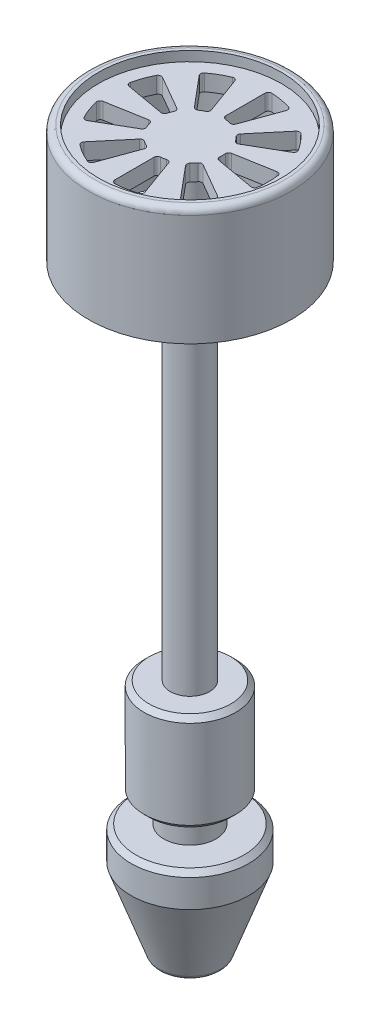
from build123d import *

# Parameters (mm, degrees)
REDONDEO1_R                       = 2
CHAFL_N1_SIZE                     = 1.5
REDONDEO2_R                       = 2
CORTAR_EXTRUIR1_REACH             = 218.983
CORTAR_EXTRUIR1_DIRECTION_2_DEPTH = 4


with BuildPart() as part:
    # Croquis1 → Revolución1 (revolve)
    with BuildSketch(Plane.XY):
        Polygon((97.681062899, 120), (97.681062899, 0), (97.681062899, -3.982649478), (89.681062899, -3.982649478), (89.681062899, -33.982649478), (95.681062899, -33.982649478), (95.681062899, -41.982649478), (85.681062899, -41.982649478), (85.681062899, -51.982649478), (94.681062899, -76.982649478), (97.681062899, -76.982649478), (97.681062899, -60.982649478), (103.681062899, -60.982649478), (103.681062899, 140), (75.681062899, 140), (75.681062899, 143), (72.681062899, 143), (72.681062899, 107), (75.681062899, 107), (75.681062899, 135), (97.681062899, 135), align=None)
    revolve(axis=Axis((103.681062899, -60.982649478, 0), (0, 1, 0)))

    # Redondeo1
    redondeo1_edges = [part.edges().sort_by_distance(p)[0] for p in [
        (134.681062899, 143, 0),
    ]]
    fillet(redondeo1_edges, radius=REDONDEO1_R)

    # Chaflán1
    chafl_n1_edges = [part.edges().sort_by_distance(p)[0] for p in [
        (121.681062899, -41.982649478, 0),
        (117.681062899, -33.982649478, 0),
        (117.681062899, -3.982649478, 0),
    ]]
    chamfer(chafl_n1_edges, length=CHAFL_N1_SIZE)

    # Redondeo2
    redondeo2_edges = [part.edges().sort_by_distance(p)[0] for p in [
        (112.681062899, -76.982649478, 0),
    ]]
    fillet(redondeo2_edges, radius=REDONDEO2_R)

    # Croquis2 → Cortar-Extruir1 (cut, up to next)
    with BuildSketch(Plane(origin=(0, 140, 0), x_dir=(1, 0, 0), z_dir=(0, 1, 0)), mode=Mode.PRIVATE) as cortar_extruir1_sk1:
        with BuildLine():
            Line((103.681062899, 10.95445115), (103.681062899, 22.978250586))
            ThreePointArc((103.681062899, 22.978250586), (103.989498824, 23.700565705), (104.72454116, 23.977304959))
            ThreePointArc((104.72454116, 23.977304959), (107.848619163, 23.635386072), (110.901235356, 22.888187121))
            ThreePointArc((110.901235356, 22.888187121), (111.497298816, 22.376738), (111.540087458, 21.592492514))
            Line((111.540087458, 21.592492514), (107.427705852, 10.293816911))
            ThreePointArc((107.427705852, 10.293816911), (106.951432292, 9.749697802), (106.232835928, 9.668942776))
            ThreePointArc((106.232835928, 9.668942776), (105.417544676, 9.84807753), (104.590153808, 9.958591955))
            ThreePointArc((104.590153808, 9.958591955), (103.942513953, 10.280251288), (103.681062899, 10.95445115))
        make_face()
    cortar_extruir1_tool1 = extrude(cortar_extruir1_sk1.sketch, amount=-CORTAR_EXTRUIR1_REACH, mode=Mode.PRIVATE) & part.part
    add(cortar_extruir1_tool1.solids().sort_by_distance((106.784802, 140, -17.602181))[0], mode=Mode.SUBTRACT)
    # Croquis2 → Cortar-Extruir1 (cut, up to next)
    with BuildSketch(Plane(origin=(0, 140, 0), x_dir=(1, 0, 0), z_dir=(0, 1, 0)), mode=Mode.PRIVATE) as cortar_extruir1_sk2:
        with BuildLine():
            Line((110.722448369, 8.391596431), (118.451197668, 17.602361174))
            ThreePointArc((118.451197668, 17.602361174), (119.151768503, 17.957427866), (119.892728164, 17.696946328))
            ThreePointArc((119.892728164, 17.696946328), (122.066129534, 15.426902632), (123.924278978, 12.892331162))
            ThreePointArc((123.924278978, 12.892331162), (124.052136921, 12.117396199), (123.580811641, 11.489125293))
            Line((123.580811641, 11.489125293), (113.16789588, 5.477225575))
            ThreePointArc((113.16789588, 5.477225575), (112.453296145, 5.366548899), (111.850911063, 5.766591799))
            ThreePointArc((111.850911063, 5.766591799), (111.34150733, 6.427876097), (110.778726457, 7.044371656))
            ThreePointArc((110.778726457, 7.044371656), (110.489364179, 7.707071875), (110.722448369, 8.391596431))
        make_face()
    cortar_extruir1_tool2 = extrude(cortar_extruir1_sk2.sketch, amount=-CORTAR_EXTRUIR1_REACH, mode=Mode.PRIVATE) & part.part
    add(cortar_extruir1_tool2.solids().sort_by_distance((117.373129, 140, -11.489008))[0], mode=Mode.SUBTRACT)
    # Croquis2 → Cortar-Extruir1 (cut, up to next)
    with BuildSketch(Plane(origin=(0, 140, 0), x_dir=(1, 0, 0), z_dir=(0, 1, 0)), mode=Mode.PRIVATE) as cortar_extruir1_sk3:
        with BuildLine():
            Line((114.469091322, 1.90222048), (126.310222227, 3.99013134))
            ThreePointArc((126.310222227, 3.99013134), (127.075123092, 3.811809954), (127.475296818, 3.13598983))
            ThreePointArc((127.475296818, 3.13598983), (127.681062899, 0), (127.475296818, -3.13598983))
            ThreePointArc((127.475296818, -3.13598983), (127.075123092, -3.811809954), (126.310222227, -3.99013134))
            Line((126.310222227, -3.99013134), (114.469091322, -1.90222048))
            ThreePointArc((114.469091322, -1.90222048), (113.850534569, -1.527667877), (113.646223445, -0.83401157))
            ThreePointArc((113.646223445, -0.83401157), (113.681062899, 0), (113.646223445, 0.83401157))
            ThreePointArc((113.646223445, 0.83401157), (113.850534569, 1.527667877), (114.469091322, 1.90222048))
        make_face()
    cortar_extruir1_tool3 = extrude(cortar_extruir1_sk3.sketch, amount=-CORTAR_EXTRUIR1_REACH, mode=Mode.PRIVATE) & part.part
    add(cortar_extruir1_tool3.solids().sort_by_distance((121.554786, 140, 0))[0], mode=Mode.SUBTRACT)
    # Croquis2 → Cortar-Extruir1 (cut, up to next)
    with BuildSketch(Plane(origin=(0, 140, 0), x_dir=(1, 0, 0), z_dir=(0, 1, 0)), mode=Mode.PRIVATE) as cortar_extruir1_sk4:
        with BuildLine():
            Line((113.16789588, -5.477225575), (123.580811641, -11.489125293))
            ThreePointArc((123.580811641, -11.489125293), (124.052136921, -12.117396199), (123.924278978, -12.892331162))
            ThreePointArc((123.924278978, -12.892331162), (122.066129534, -15.426902632), (119.892728164, -17.696946328))
            ThreePointArc((119.892728164, -17.696946328), (119.151768503, -17.957427866), (118.451197668, -17.602361174))
            Line((118.451197668, -17.602361174), (110.722448369, -8.391596431))
            ThreePointArc((110.722448369, -8.391596431), (110.489364179, -7.707071875), (110.778726457, -7.044371656))
            ThreePointArc((110.778726457, -7.044371656), (111.34150733, -6.427876097), (111.850911063, -5.766591799))
            ThreePointArc((111.850911063, -5.766591799), (112.453296145, -5.366548899), (113.16789588, -5.477225575))
        make_face()
    cortar_extruir1_tool4 = extrude(cortar_extruir1_sk4.sketch, amount=-CORTAR_EXTRUIR1_REACH, mode=Mode.PRIVATE) & part.part
    add(cortar_extruir1_tool4.solids().sort_by_distance((117.373129, 140, 11.489008))[0], mode=Mode.SUBTRACT)
    # Croquis2 → Cortar-Extruir1 (cut, up to next)
    with BuildSketch(Plane(origin=(0, 140, 0), x_dir=(1, 0, 0), z_dir=(0, 1, 0)), mode=Mode.PRIVATE) as cortar_extruir1_sk5:
        with BuildLine():
            Line((103.681062899, -10.95445115), (103.681062899, -22.978250586))
            ThreePointArc((103.681062899, -22.978250586), (103.989498824, -23.700565705), (104.72454116, -23.977304959))
            ThreePointArc((104.72454116, -23.977304959), (107.848619163, -23.635386072), (110.901235356, -22.888187121))
            ThreePointArc((110.901235356, -22.888187121), (111.497298816, -22.376738), (111.540087458, -21.592492514))
            Line((111.540087458, -21.592492514), (107.427705852, -10.293816911))
            ThreePointArc((107.427705852, -10.293816911), (106.951432292, -9.749697802), (106.232835928, -9.668942776))
            ThreePointArc((106.232835928, -9.668942776), (105.417544676, -9.84807753), (104.590153808, -9.958591955))
            ThreePointArc((104.590153808, -9.958591955), (103.942513953, -10.280251288), (103.681062899, -10.95445115))
        make_face()
    cortar_extruir1_tool5 = extrude(cortar_extruir1_sk5.sketch, amount=-CORTAR_EXTRUIR1_REACH, mode=Mode.PRIVATE) & part.part
    add(cortar_extruir1_tool5.solids().sort_by_distance((106.784802, 140, 17.602181))[0], mode=Mode.SUBTRACT)
    # Croquis2 → Cortar-Extruir1 (cut, up to next)
    with BuildSketch(Plane(origin=(0, 140, 0), x_dir=(1, 0, 0), z_dir=(0, 1, 0)), mode=Mode.PRIVATE) as cortar_extruir1_sk6:
        with BuildLine():
            Line((99.934419947, -10.293816911), (95.82203834, -21.592492514))
            ThreePointArc((95.82203834, -21.592492514), (95.285157057, -22.165755402), (94.499792799, -22.174405952))
            ThreePointArc((94.499792799, -22.174405952), (91.681062899, -20.784609691), (89.068099081, -19.038416122))
            ThreePointArc((89.068099081, -19.038416122), (88.682908548, -18.353945448), (88.91092813, -17.602361174))
            Line((88.91092813, -17.602361174), (96.639677429, -8.391596431))
            ThreePointArc((96.639677429, -8.391596431), (97.273327874, -8.043186871), (97.97620742, -8.213076401))
            ThreePointArc((97.97620742, -8.213076401), (98.681062899, -8.660254038), (99.420757833, -9.04708797))
            ThreePointArc((99.420757833, -9.04708797), (99.919326254, -9.570854748), (99.934419947, -10.293816911))
        make_face()
    cortar_extruir1_tool6 = extrude(cortar_extruir1_sk6.sketch, amount=-CORTAR_EXTRUIR1_REACH, mode=Mode.PRIVATE) & part.part
    add(cortar_extruir1_tool6.solids().sort_by_distance((94.744201, 140, 15.479098))[0], mode=Mode.SUBTRACT)
    # Croquis2 → Cortar-Extruir1 (cut, up to next)
    with BuildSketch(Plane(origin=(0, 140, 0), x_dir=(1, 0, 0), z_dir=(0, 1, 0)), mode=Mode.PRIVATE) as cortar_extruir1_sk7:
        with BuildLine():
            Line((94.194229919, -5.477225575), (83.781314157, -11.489125293))
            ThreePointArc((83.781314157, -11.489125293), (83.001552952, -11.583169506), (82.39436856, -11.084973798))
            ThreePointArc((82.39436856, -11.084973798), (81.12844, -8.20848344), (80.249225177, -5.191240793))
            ThreePointArc((80.249225177, -5.191240793), (80.394121379, -4.419310135), (81.051903571, -3.99013134))
            Line((81.051903571, -3.99013134), (92.893034477, -1.90222048))
            ThreePointArc((92.893034477, -1.90222048), (93.602392227, -2.042625927), (94.031626313, -2.624571121))
            ThreePointArc((94.031626313, -2.624571121), (94.284136691, -3.420201433), (94.602123826, -4.192000156))
            ThreePointArc((94.602123826, -4.192000156), (94.6473786, -4.913702389), (94.194229919, -5.477225575))
        make_face()
    cortar_extruir1_tool7 = extrude(cortar_extruir1_sk7.sketch, amount=-CORTAR_EXTRUIR1_REACH, mode=Mode.PRIVATE) & part.part
    add(cortar_extruir1_tool7.solids().sort_by_distance((86.885257, 140, 6.113173))[0], mode=Mode.SUBTRACT)
    # Croquis2 → Cortar-Extruir1 (cut, up to next)
    with BuildSketch(Plane(origin=(0, 140, 0), x_dir=(1, 0, 0), z_dir=(0, 1, 0)), mode=Mode.PRIVATE) as cortar_extruir1_sk8:
        with BuildLine():
            Line((92.893034477, 1.90222048), (81.051903571, 3.99013134))
            ThreePointArc((81.051903571, 3.99013134), (80.394121379, 4.419310135), (80.249225177, 5.191240793))
            ThreePointArc((80.249225177, 5.191240793), (81.12844, 8.20848344), (82.39436856, 11.084973798))
            ThreePointArc((82.39436856, 11.084973798), (83.001552952, 11.583169506), (83.781314157, 11.489125293))
            Line((83.781314157, 11.489125293), (94.194229919, 5.477225575))
            ThreePointArc((94.194229919, 5.477225575), (94.6473786, 4.913702389), (94.602123826, 4.192000156))
            ThreePointArc((94.602123826, 4.192000156), (94.284136691, 3.420201433), (94.031626313, 2.624571121))
            ThreePointArc((94.031626313, 2.624571121), (93.602392227, 2.042625927), (92.893034477, 1.90222048))
        make_face()
    cortar_extruir1_tool8 = extrude(cortar_extruir1_sk8.sketch, amount=-CORTAR_EXTRUIR1_REACH, mode=Mode.PRIVATE) & part.part
    add(cortar_extruir1_tool8.solids().sort_by_distance((86.885257, 140, -6.113173))[0], mode=Mode.SUBTRACT)
    # Croquis2 → Cortar-Extruir1 (cut, up to next)
    with BuildSketch(Plane(origin=(0, 140, 0), x_dir=(1, 0, 0), z_dir=(0, 1, 0)), mode=Mode.PRIVATE) as cortar_extruir1_sk9:
        with BuildLine():
            Line((96.639677429, 8.391596431), (88.91092813, 17.602361174))
            ThreePointArc((88.91092813, 17.602361174), (88.682908548, 18.353945448), (89.068099081, 19.038416122))
            ThreePointArc((89.068099081, 19.038416122), (91.681062899, 20.784609691), (94.499792799, 22.174405952))
            ThreePointArc((94.499792799, 22.174405952), (95.285157057, 22.165755402), (95.82203834, 21.592492514))
            Line((95.82203834, 21.592492514), (99.934419947, 10.293816911))
            ThreePointArc((99.934419947, 10.293816911), (99.919326254, 9.570854748), (99.420757833, 9.04708797))
            ThreePointArc((99.420757833, 9.04708797), (98.681062899, 8.660254038), (97.97620742, 8.213076401))
            ThreePointArc((97.97620742, 8.213076401), (97.273327874, 8.043186871), (96.639677429, 8.391596431))
        make_face()
    cortar_extruir1_tool9 = extrude(cortar_extruir1_sk9.sketch, amount=-CORTAR_EXTRUIR1_REACH, mode=Mode.PRIVATE) & part.part
    add(cortar_extruir1_tool9.solids().sort_by_distance((94.744201, 140, -15.479098))[0], mode=Mode.SUBTRACT)

    # Croquis2 → Cortar-Extruir1 direction 2 (cut)
    with BuildSketch(Plane(origin=(0, 140, 0), x_dir=(1, 0, 0), z_dir=(0, 1, 0))):
        with BuildLine():
            Line((103.681062899, 10.95445115), (103.681062899, 22.978250586))
            ThreePointArc((103.681062899, 22.978250586), (103.989498824, 23.700565705), (104.72454116, 23.977304959))
            ThreePointArc((104.72454116, 23.977304959), (107.848619163, 23.635386072), (110.901235356, 22.888187121))
            ThreePointArc((110.901235356, 22.888187121), (111.497298816, 22.376738), (111.540087458, 21.592492514))
            Line((111.540087458, 21.592492514), (107.427705852, 10.293816911))
            ThreePointArc((107.427705852, 10.293816911), (106.951432292, 9.749697802), (106.232835928, 9.668942776))
            ThreePointArc((106.232835928, 9.668942776), (105.417544676, 9.84807753), (104.590153808, 9.958591955))
            ThreePointArc((104.590153808, 9.958591955), (103.942513953, 10.280251288), (103.681062899, 10.95445115))
        make_face()
        with BuildLine():
            Line((110.722448369, 8.391596431), (118.451197668, 17.602361174))
            ThreePointArc((118.451197668, 17.602361174), (119.151768503, 17.957427866), (119.892728164, 17.696946328))
            ThreePointArc((119.892728164, 17.696946328), (122.066129534, 15.426902632), (123.924278978, 12.892331162))
            ThreePointArc((123.924278978, 12.892331162), (124.052136921, 12.117396199), (123.580811641, 11.489125293))
            Line((123.580811641, 11.489125293), (113.16789588, 5.477225575))
            ThreePointArc((113.16789588, 5.477225575), (112.453296145, 5.366548899), (111.850911063, 5.766591799))
            ThreePointArc((111.850911063, 5.766591799), (111.34150733, 6.427876097), (110.778726457, 7.044371656))
            ThreePointArc((110.778726457, 7.044371656), (110.489364179, 7.707071875), (110.722448369, 8.391596431))
        make_face()
        with BuildLine():
            Line((114.469091322, 1.90222048), (126.310222227, 3.99013134))
            ThreePointArc((126.310222227, 3.99013134), (127.075123092, 3.811809954), (127.475296818, 3.13598983))
            ThreePointArc((127.475296818, 3.13598983), (127.681062899, 0), (127.475296818, -3.13598983))
            ThreePointArc((127.475296818, -3.13598983), (127.075123092, -3.811809954), (126.310222227, -3.99013134))
            Line((126.310222227, -3.99013134), (114.469091322, -1.90222048))
            ThreePointArc((114.469091322, -1.90222048), (113.850534569, -1.527667877), (113.646223445, -0.83401157))
            ThreePointArc((113.646223445, -0.83401157), (113.681062899, 0), (113.646223445, 0.83401157))
            ThreePointArc((113.646223445, 0.83401157), (113.850534569, 1.527667877), (114.469091322, 1.90222048))
        make_face()
        with BuildLine():
            Line((113.16789588, -5.477225575), (123.580811641, -11.489125293))
            ThreePointArc((123.580811641, -11.489125293), (124.052136921, -12.117396199), (123.924278978, -12.892331162))
            ThreePointArc((123.924278978, -12.892331162), (122.066129534, -15.426902632), (119.892728164, -17.696946328))
            ThreePointArc((119.892728164, -17.696946328), (119.151768503, -17.957427866), (118.451197668, -17.602361174))
            Line((118.451197668, -17.602361174), (110.722448369, -8.391596431))
            ThreePointArc((110.722448369, -8.391596431), (110.489364179, -7.707071875), (110.778726457, -7.044371656))
            ThreePointArc((110.778726457, -7.044371656), (111.34150733, -6.427876097), (111.850911063, -5.766591799))
            ThreePointArc((111.850911063, -5.766591799), (112.453296145, -5.366548899), (113.16789588, -5.477225575))
        make_face()
        with BuildLine():
            Line((103.681062899, -10.95445115), (103.681062899, -22.978250586))
            ThreePointArc((103.681062899, -22.978250586), (103.989498824, -23.700565705), (104.72454116, -23.977304959))
            ThreePointArc((104.72454116, -23.977304959), (107.848619163, -23.635386072), (110.901235356, -22.888187121))
            ThreePointArc((110.901235356, -22.888187121), (111.497298816, -22.376738), (111.540087458, -21.592492514))
            Line((111.540087458, -21.592492514), (107.427705852, -10.293816911))
            ThreePointArc((107.427705852, -10.293816911), (106.951432292, -9.749697802), (106.232835928, -9.668942776))
            ThreePointArc((106.232835928, -9.668942776), (105.417544676, -9.84807753), (104.590153808, -9.958591955))
            ThreePointArc((104.590153808, -9.958591955), (103.942513953, -10.280251288), (103.681062899, -10.95445115))
        make_face()
        with BuildLine():
            Line((99.934419947, -10.293816911), (95.82203834, -21.592492514))
            ThreePointArc((95.82203834, -21.592492514), (95.285157057, -22.165755402), (94.499792799, -22.174405952))
            ThreePointArc((94.499792799, -22.174405952), (91.681062899, -20.784609691), (89.068099081, -19.038416122))
            ThreePointArc((89.068099081, -19.038416122), (88.682908548, -18.353945448), (88.91092813, -17.602361174))
            Line((88.91092813, -17.602361174), (96.639677429, -8.391596431))
            ThreePointArc((96.639677429, -8.391596431), (97.273327874, -8.043186871), (97.97620742, -8.213076401))
            ThreePointArc((97.97620742, -8.213076401), (98.681062899, -8.660254038), (99.420757833, -9.04708797))
            ThreePointArc((99.420757833, -9.04708797), (99.919326254, -9.570854748), (99.934419947, -10.293816911))
        make_face()
        with BuildLine():
            Line((94.194229919, -5.477225575), (83.781314157, -11.489125293))
            ThreePointArc((83.781314157, -11.489125293), (83.001552952, -11.583169506), (82.39436856, -11.084973798))
            ThreePointArc((82.39436856, -11.084973798), (81.12844, -8.20848344), (80.249225177, -5.191240793))
            ThreePointArc((80.249225177, -5.191240793), (80.394121379, -4.419310135), (81.051903571, -3.99013134))
            Line((81.051903571, -3.99013134), (92.893034477, -1.90222048))
            ThreePointArc((92.893034477, -1.90222048), (93.602392227, -2.042625927), (94.031626313, -2.624571121))
            ThreePointArc((94.031626313, -2.624571121), (94.284136691, -3.420201433), (94.602123826, -4.192000156))
            ThreePointArc((94.602123826, -4.192000156), (94.6473786, -4.913702389), (94.194229919, -5.477225575))
        make_face()
        with BuildLine():
            Line((92.893034477, 1.90222048), (81.051903571, 3.99013134))
            ThreePointArc((81.051903571, 3.99013134), (80.394121379, 4.419310135), (80.249225177, 5.191240793))
            ThreePointArc((80.249225177, 5.191240793), (81.12844, 8.20848344), (82.39436856, 11.084973798))
            ThreePointArc((82.39436856, 11.084973798), (83.001552952, 11.583169506), (83.781314157, 11.489125293))
            Line((83.781314157, 11.489125293), (94.194229919, 5.477225575))
            ThreePointArc((94.194229919, 5.477225575), (94.6473786, 4.913702389), (94.602123826, 4.192000156))
            ThreePointArc((94.602123826, 4.192000156), (94.284136691, 3.420201433), (94.031626313, 2.624571121))
            ThreePointArc((94.031626313, 2.624571121), (93.602392227, 2.042625927), (92.893034477, 1.90222048))
        make_face()
        with BuildLine():
            Line((96.639677429, 8.391596431), (88.91092813, 17.602361174))
            ThreePointArc((88.91092813, 17.602361174), (88.682908548, 18.353945448), (89.068099081, 19.038416122))
            ThreePointArc((89.068099081, 19.038416122), (91.681062899, 20.784609691), (94.499792799, 22.174405952))
            ThreePointArc((94.499792799, 22.174405952), (95.285157057, 22.165755402), (95.82203834, 21.592492514))
            Line((95.82203834, 21.592492514), (99.934419947, 10.293816911))
            ThreePointArc((99.934419947, 10.293816911), (99.919326254, 9.570854748), (99.420757833, 9.04708797))
            ThreePointArc((99.420757833, 9.04708797), (98.681062899, 8.660254038), (97.97620742, 8.213076401))
            ThreePointArc((97.97620742, 8.213076401), (97.273327874, 8.043186871), (96.639677429, 8.391596431))
        make_face()
    extrude(amount=CORTAR_EXTRUIR1_DIRECTION_2_DEPTH, mode=Mode.SUBTRACT)


solid = part.part
